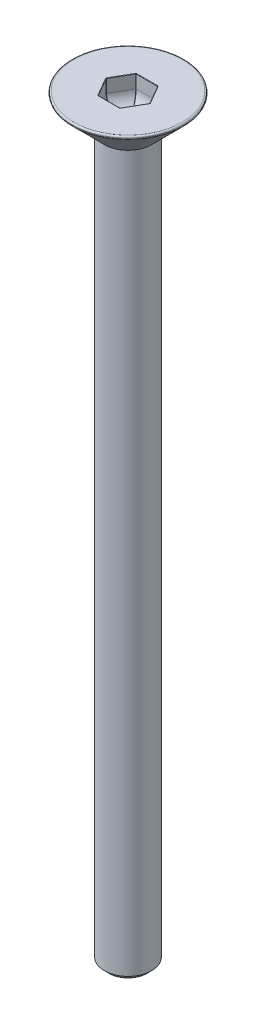
from build123d import *

# Parameters (mm, degrees)
SKETCH8_W          = 1.25
SKETCH8_H          = 40
CHAMFER1_SIZE      = 0.25
CHAMFER2_SIZE2     = 0.2
CHAMFER2_SIZE      = 0.141421
FILLET1_R          = 0.08
CUT_EXTRUDE1_DEPTH = 1.5
FILLET2_R          = 0.8
FILLET5_R          = 0.02


with BuildPart() as part:
    # Sketch8 → Revolve1 (revolve)
    with BuildSketch(Plane.XY):
        with Locations((0.625, -20)):
            Rectangle(SKETCH8_W, SKETCH8_H)
    revolve(axis=Axis((0, 0, 0), (0, -1, 0)))

    # Chamfer1
    chamfer1_edges = [part.edges().sort_by_distance(p)[0] for p in [
        (-1.25, -40, 0),
    ]]
    chamfer(chamfer1_edges, length=CHAMFER1_SIZE)

    # Sketch13 → Revolve2 (revolve)
    with BuildSketch(Plane.XY):
        Polygon((0, 0), (3.1, 0), (0, -3.1), align=None)
    revolve(axis=Axis((0, 0, 0), (0, -1, 0)))

    # Chamfer2
    chamfer2_edges = [part.edges().sort_by_distance(p)[0] for p in [
        (-3.1, 0, 0),
    ]]
    chamfer(chamfer2_edges, length=CHAMFER2_SIZE, length2=CHAMFER2_SIZE2)

    # Fillet1
    fillet1_edges = [part.edges().sort_by_distance(p)[0] for p in [
        (-2.958578, 0, 0),
        (-2.958578, -0.141421, 0),
    ]]
    fillet(fillet1_edges, radius=FILLET1_R)

    # Sketch14 → Cut-Extrude1 (cut)
    with BuildSketch(Plane(origin=(0, 0, 0), x_dir=(1, 0, 0), z_dir=(0, 1, 0))):
        Polygon((1.154701, 0), (0.57735, 1), (-0.57735, 1), (-1.154701, 0), (-0.57735, -1), (0.57735, -1), align=None)
    extrude(amount=-CUT_EXTRUDE1_DEPTH, mode=Mode.SUBTRACT)

    # Fillet2
    fillet2_edges = [part.edges().sort_by_distance(p)[0] for p in [
        (0.866025, -1.5, 0.5),
        (0, -1.5, 1),
        (-0.866025, -1.5, 0.5),
        (-0.866025, -1.5, -0.5),
        (0, -1.5, -1),
        (0.866025, -1.5, -0.5),
    ]]
    fillet(fillet2_edges, radius=FILLET2_R)

    # Fillet5
    fillet5_edges = [part.edges().sort_by_distance(p)[0] for p in [
        (0.866025, 0, 0.5),
        (0.866025, 0, -0.5),
        (0, 0, -1),
        (-0.866025, 0, -0.5),
        (-0.866025, 0, 0.5),
        (0, 0, 1),
        (0.57735, -0.35, 1),
        (-0.57735, -0.35, 1),
        (-1.154701, -0.35, 0),
        (-0.57735, -0.35, -1),
        (0.57735, -0.35, -1),
        (1.154701, -0.35, 0),
        (-0.430209, -1.285507, -0.745143),
        (0.430209, -1.285507, -0.745143),
        (-0.860417, -1.285507, 0),
        (0.860417, -1.285507, 0),
        (-0.430209, -1.285507, 0.745143),
        (0.430209, -1.285507, 0.745143),
    ]]
    fillet(fillet5_edges, radius=FILLET5_R)


solid = part.part
